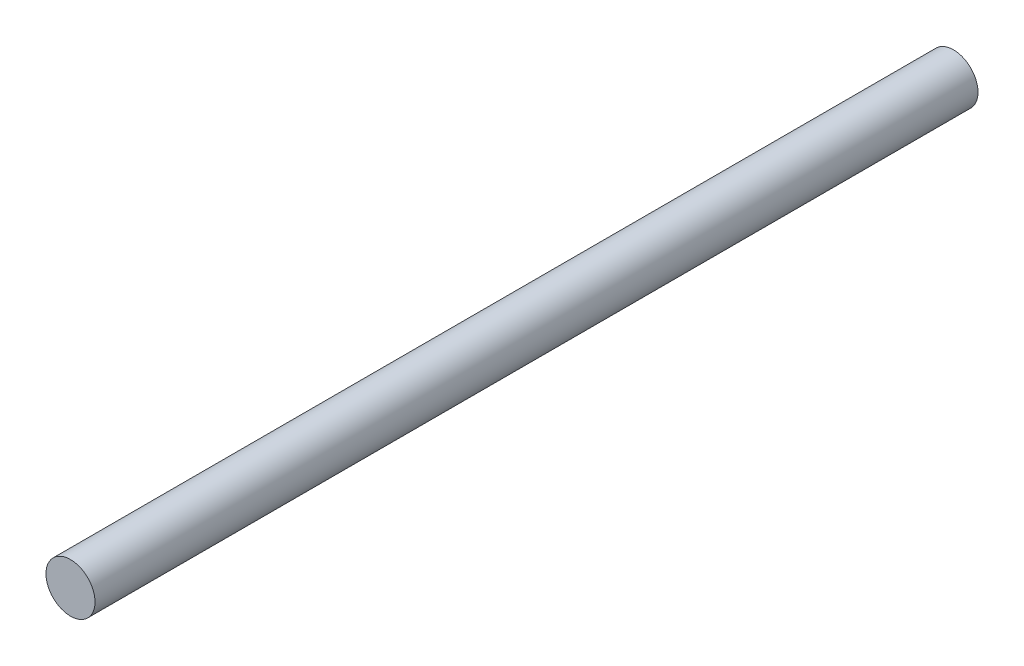
from build123d import *

# Parameters (mm, degrees)
SKETCH3_R                = 25.4
BOSS_EXTRUDE1_DEPTH      = 457.2
BOSS_EXTRUDE1_DEPTH_BACK = 457.2


with BuildPart() as part:
    # Sketch3 → Boss-Extrude1 (new body, two sides)
    with BuildSketch(Plane.XY) as boss_extrude1_sk:
        Circle(SKETCH3_R)
    extrude(amount=BOSS_EXTRUDE1_DEPTH)
    extrude(boss_extrude1_sk.sketch, amount=-BOSS_EXTRUDE1_DEPTH_BACK)


solid = part.part
